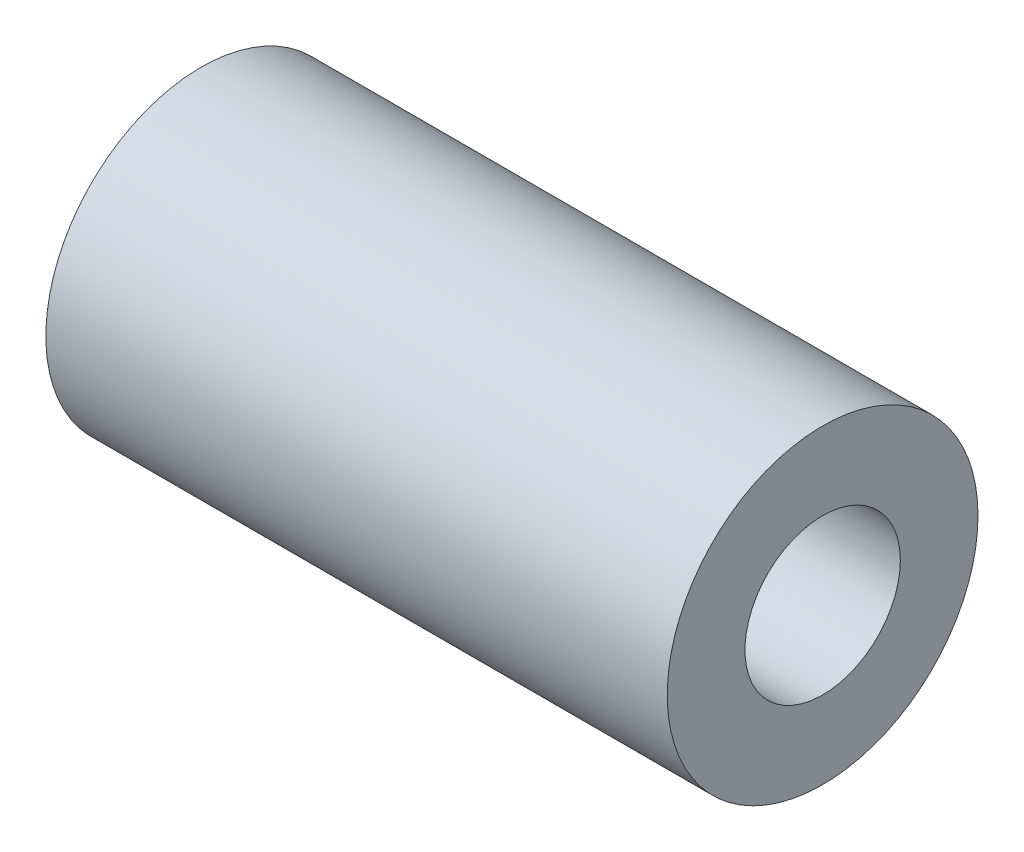
from build123d import *

# Parameters (mm, degrees)
SKETCH1_W = 200
SKETCH1_H = 25


with BuildPart() as part:
    # Sketch1 → Revolve1 (revolve)
    with BuildSketch(Plane.XY):
        with Locations((-40.456117376, 37.5)):
            Rectangle(SKETCH1_W, SKETCH1_H)
    revolve(axis=Axis((0, 0, 0), (-1, 0, 0)))


solid = part.part
